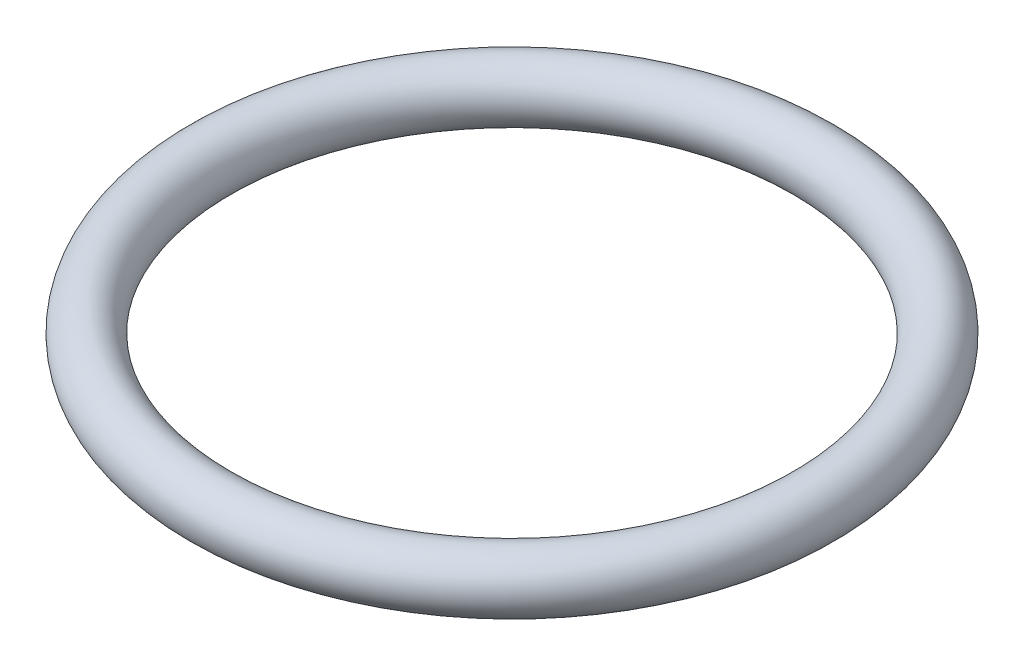
from build123d import *

# Parameters (mm, degrees)
ESQUISSE1_R = 1.31


with BuildPart() as part:
    # Esquisse1 → Révolution1 (revolve)
    with BuildSketch(Plane.XY):
        with Locations((13.81, 0)):
            Circle(ESQUISSE1_R)
    revolve(axis=Axis((0, 9.544226001, 0), (0, -1, 0)))


solid = part.part
